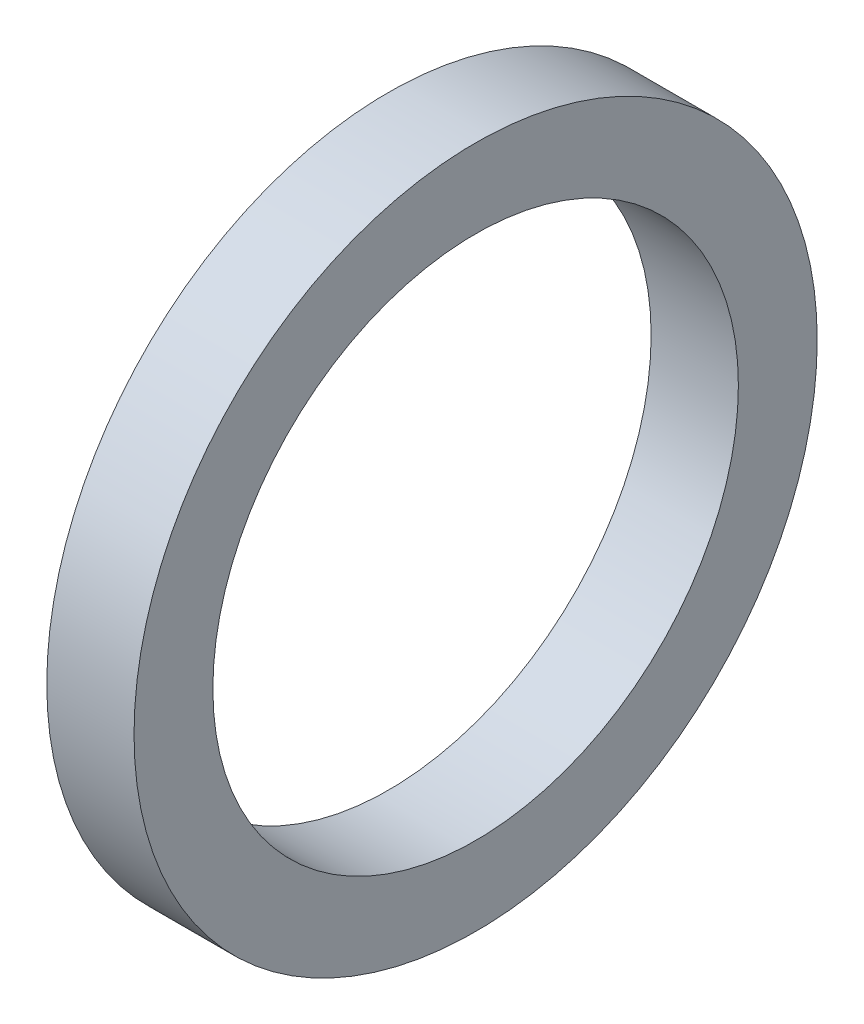
from build123d import *

# Parameters (mm, degrees)
SKETCH3_W = 9.959999892
SKETCH3_H = 9.000000034


with BuildPart() as part:
    # Sketch3 → Revolve1 (revolve)
    with BuildSketch(Plane.XY):
        with Locations((-6.79519977, 34.499999961)):
            Rectangle(SKETCH3_W, SKETCH3_H)
    revolve(axis=Axis((0, 0, 0), (1, 0, 0)))


solid = part.part
